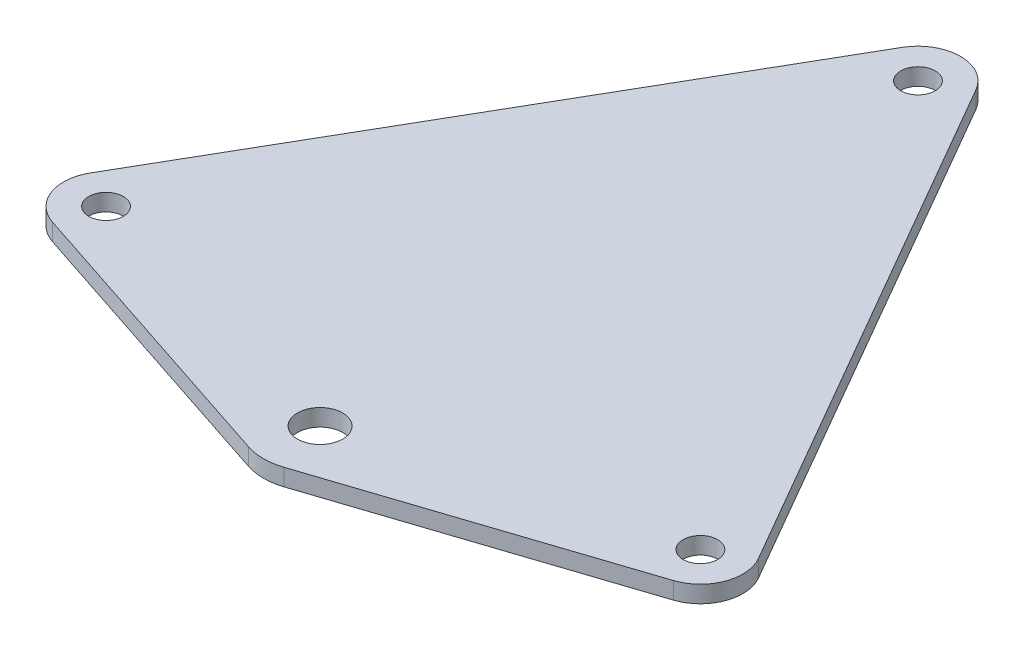
from build123d import *

# Parameters (mm, degrees)
SKETCH1_R           = 3.05
SKETCH1_R_2         = 4
BOSS_EXTRUDE1_DEPTH = 3


with BuildPart() as part:
    # Sketch1 → Boss-Extrude1 (new body)
    with BuildSketch(Plane(origin=(0, 0, 0), x_dir=(1, 0, 0), z_dir=(0, 1, 0))):
        with BuildLine():
            Line((6.495190528, 64.371778265), (58.995190528, -26.560889132))
            ThreePointArc((58.995190528, -26.560889132), (58.995190528, -34.060889132), (52.5, -37.810889132))
            Line((52.5, -37.810889132), (-52.5, -37.810889132))
            ThreePointArc((-52.5, -37.810889132), (-58.995190528, -34.060889132), (-58.995190528, -26.560889132))
            Line((-58.995190528, -26.560889132), (-6.495190528, 64.371778265))
            ThreePointArc((-6.495190528, 64.371778265), (0, 68.121778265), (6.495190528, 64.371778265))
        make_face()
        with Locations((-52.5, -30.310889132)):
            Circle(SKETCH1_R, mode=Mode.SUBTRACT)
        with Locations((52.5, -30.310889132)):
            Circle(SKETCH1_R, mode=Mode.SUBTRACT)
        with Locations((0, 60.621778265)):
            Circle(SKETCH1_R, mode=Mode.SUBTRACT)
        with BuildLine():
            ThreePointArc((-52.5, -37.810889132), (-53.69003782, -37.715874614), (-54.849923408, -37.433238462))
            Line((-54.849923408, -37.433238462), (-3.133231211, -54.496465773))
            ThreePointArc((-3.133231211, -54.496465773), (0, -55), (3.133231211, -54.496465773))
            Line((3.133231211, -54.496465773), (54.849923408, -37.433238462))
            ThreePointArc((54.849923408, -37.433238462), (53.69003782, -37.715874614), (52.5, -37.810889132))
            Line((52.5, -37.810889132), (-52.5, -37.810889132))
        make_face()
        with Locations((0, -45)):
            Circle(SKETCH1_R_2, mode=Mode.SUBTRACT)
    extrude(amount=BOSS_EXTRUDE1_DEPTH)


solid = part.part
